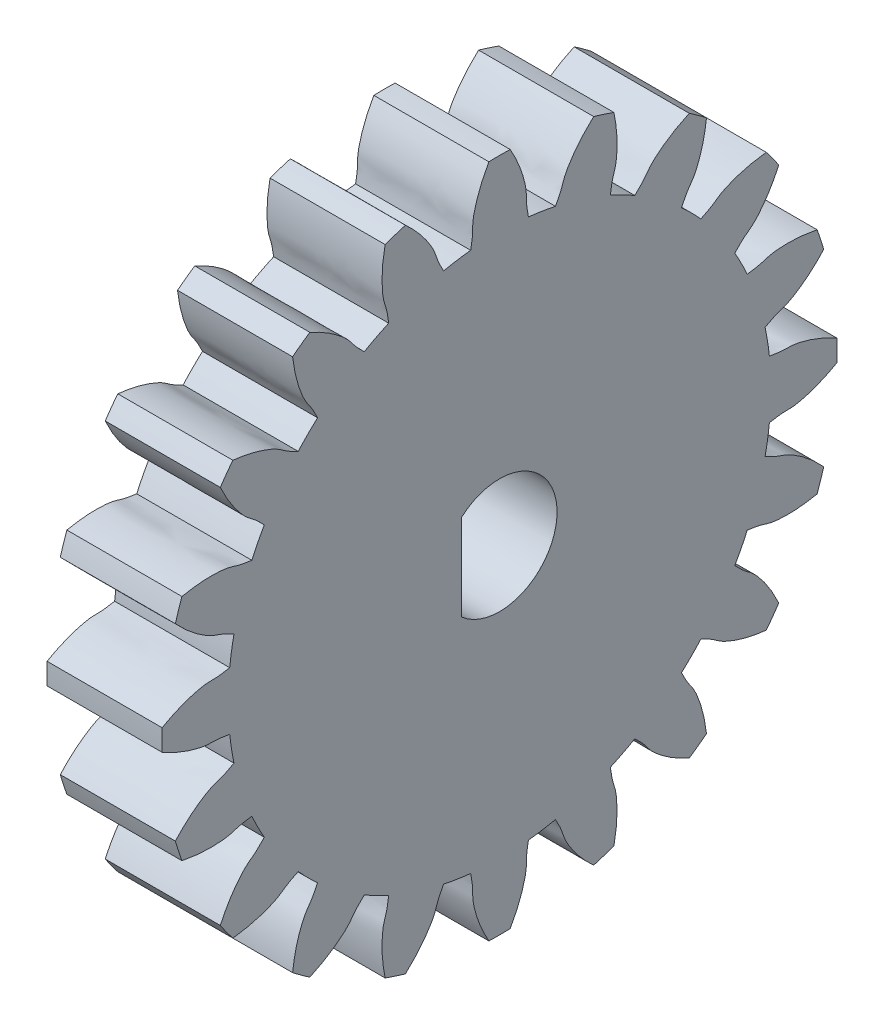
from build123d import *

# Parameters (mm, degrees)
SKETCH41_W          = 3
SKETCH41_H          = 8.8
CUT_EXTRUDE22_DEPTH = 4
CUT_EXTRUDE23_DEPTH = 4.0000001
CUT_EXTRUDE24_DEPTH = 4.0000001
CUT_EXTRUDE25_DEPTH = 4.0000001
CUT_EXTRUDE26_DEPTH = 4.0000001
CUT_EXTRUDE27_DEPTH = 4.0000001
CUT_EXTRUDE28_DEPTH = 4.0000001
CUT_EXTRUDE29_DEPTH = 4.0000001
CUT_EXTRUDE30_DEPTH = 4.0000001
CUT_EXTRUDE31_DEPTH = 4.0000001
CUT_EXTRUDE32_DEPTH = 4.0000001
CUT_EXTRUDE33_DEPTH = 4.0000001
CUT_EXTRUDE34_DEPTH = 4.0000001
CUT_EXTRUDE35_DEPTH = 4.0000001
CUT_EXTRUDE36_DEPTH = 4.0000001
CUT_EXTRUDE37_DEPTH = 4.0000001
CUT_EXTRUDE38_DEPTH = 4.0000001
CUT_EXTRUDE39_DEPTH = 4.0000001
CUT_EXTRUDE40_DEPTH = 4.0000001
CUT_EXTRUDE41_DEPTH = 4.0000001
SKETCH192_R         = 1.5
CUT_EXTRUDE42_DEPTH = 4.0000001
BOSS_EXTRUDE1_DEPTH = 3


with BuildPart() as part:
    # Sketch41 → Revolve3 (revolve)
    with BuildSketch(Plane.XY):
        with Locations((0, 4.4)):
            Rectangle(SKETCH41_W, SKETCH41_H)
    revolve(axis=Axis((-1.5, 0, 0), (1, 0, 0)))

    # Sketch47 → Cut-Extrude22 (cut, through all)
    with BuildSketch(Plane.ZY.offset(1.5)):
        with BuildLine():
            ThreePointArc((0.752371374, 7.034278405), (1.10668029, 6.987302347), (1.458164488, 6.922491725))
            add(Edge.make_bspline(
                [(1.458164488, 6.922491725), (1.494423107, 6.992924065), (1.531449224, 7.062967764), (1.566855162, 7.133832576), (1.636353022, 7.272932207), (1.667486777, 7.42948987), (1.74037045, 7.566845723), (1.810588583, 7.699178127), (1.894945412, 7.824180822), (1.98539454, 7.943601953), (2.0778826, 8.065715114), (2.179505836, 8.181201544), (2.2870056, 8.290332043), (2.341161164, 8.34530913), (2.396825306, 8.398829506), (2.453689093, 8.451000523)],
                knots=[-0.000236866, -0.000236866, -0.000236866, -0.000236866, 0, 0, 0, 0.000466485, 0.000466485, 0.000466485, 0.000915119, 0.000915119, 0.000915119, 0.001373742, 0.001373742, 0.001373742, 0.001604528, 0.001604528, 0.001604528, 0.001604528], degree=3))
            ThreePointArc((2.453689093, 8.451000523), (1.376623292, 8.691657397), (0.27790578, 8.795610745))
            add(Edge.make_bspline(
                [(0.27790578, 8.795610745), (0.315864725, 8.728421283), (0.352265764, 8.660319215), (0.386781912, 8.591297908), (0.467849437, 8.429188674), (0.538210762, 8.260953031), (0.593124703, 8.088222586), (0.648214325, 7.914939536), (0.696810293, 7.735248583), (0.700775261, 7.553462553), (0.702846258, 7.45851138), (0.700191106, 7.362781606), (0.71430769, 7.26886283), (0.726082314, 7.190525298), (0.739651946, 7.11246809), (0.752371374, 7.034278405)],
                knots=[-0.000231043, -0.000231043, -0.000231043, -0.000231043, 0, 0, 0, 0.000543748, 0.000543748, 0.000543748, 0.001090684, 0.001090684, 0.001090684, 0.001371999, 0.001371999, 0.001371999, 0.001605449, 0.001605449, 0.001605449, 0.001605449], degree=3))
        make_face()
    extrude(amount=-CUT_EXTRUDE22_DEPTH, mode=Mode.SUBTRACT)

    # Sketch54 → Cut-Extrude23 (cut, through all)
    with BuildSketch(Plane.ZY.offset(1.5)):
        with BuildLine():
            ThreePointArc((2.889259268, 6.457500774), (3.211710672, 6.303336412), (3.525964424, 6.133083257))
            add(Edge.make_bspline(
                [(3.525964424, 6.133083257), (3.58221321, 6.188863864), (3.639071834, 6.24403768), (3.694643313, 6.300493085), (3.803723856, 6.411308676), (3.881712795, 6.550583001), (3.993474579, 6.658693887), (4.101148954, 6.762850886), (4.220005023, 6.85566782), (4.342930415, 6.941293747), (4.468626829, 7.028849882), (4.600963539, 7.107280697), (4.736925069, 7.177850716), (4.805418925, 7.213402042), (4.874897376, 7.247101779), (4.945099782, 7.279147488)],
                knots=[-0.000236866, -0.000236866, -0.000236866, -0.000236866, 0, 0, 0, 0.000466485, 0.000466485, 0.000466485, 0.000915119, 0.000915119, 0.000915119, 0.001373742, 0.001373742, 0.001373742, 0.001604513, 0.001604513, 0.001604513, 0.001604513], degree=3))
            ThreePointArc((4.945099782, 7.279147488), (3.995116398, 7.840857413), (2.982297299, 8.279245305))
            add(Edge.make_bspline(
                [(2.982297299, 8.279245305), (2.997635716, 8.203614371), (3.011210464, 8.127596915), (3.022708515, 8.051287675), (3.049713804, 7.872061389), (3.064643729, 7.690316939), (3.063493347, 7.509071182), (3.062339284, 7.32724558), (3.053029237, 7.141332348), (3.000625173, 6.967218317), (2.973253282, 6.876274412), (2.941145956, 6.786050473), (2.925549127, 6.692366146), (2.912539832, 6.614224166), (2.901324315, 6.535794103), (2.889259268, 6.457500774)],
                knots=[-0.000231057, -0.000231057, -0.000231057, -0.000231057, 0, 0, 0, 0.000543748, 0.000543748, 0.000543748, 0.001090684, 0.001090684, 0.001090684, 0.001371999, 0.001371999, 0.001371999, 0.001605449, 0.001605449, 0.001605449, 0.001605449], degree=3))
        make_face()
    extrude(amount=-CUT_EXTRUDE23_DEPTH, mode=Mode.SUBTRACT)

    # Sketch61 → Cut-Extrude24 (cut, through all)
    with BuildSketch(Plane.ZY.offset(1.5)):
        with BuildLine():
            ThreePointArc((4.743326335, 5.248617975), (5.002356435, 5.00235599), (5.248618396, 4.743325868))
            add(Edge.make_bspline(
                [(5.248618396, 4.743325868), (5.319351326, 4.778994547), (5.390476738, 4.813897683), (5.460774034, 4.850417433), (5.598759696, 4.922101581), (5.715969719, 5.030459428), (5.855669593, 5.0987427), (5.990260291, 5.164528681), (6.13198114, 5.216074285), (6.275350002, 5.259523346), (6.421950729, 5.303951851), (6.572046874, 5.337649696), (6.723161308, 5.362751349), (6.799288801, 5.375396904), (6.875780525, 5.385977237), (6.95244965, 5.39476078)],
                knots=[-0.000236866, -0.000236866, -0.000236866, -0.000236866, 0, 0, 0, 0.000466485, 0.000466485, 0.000466485, 0.000915119, 0.000915119, 0.000915119, 0.001373742, 0.001373742, 0.001373742, 0.001604513, 0.001604513, 0.001604513, 0.001604513], degree=3))
            ThreePointArc((6.95244965, 5.39476078), (6.222539674, 6.222539674), (5.39476078, 6.95244965))
            add(Edge.make_bspline(
                [(5.39476078, 6.95244965), (5.385977237, 6.875780525), (5.375396904, 6.799288801), (5.362751349, 6.723161308), (5.333050936, 6.544361887), (5.291088015, 6.366899043), (5.233985917, 6.194879573), (5.176701137, 6.022309774), (5.110396409, 5.848372746), (5.006752987, 5.698974209), (4.95261756, 5.620939794), (4.894200948, 5.545053439), (4.850417433, 5.460774034), (4.813897658, 5.390476688), (4.778994845, 5.319351051), (4.743326335, 5.248617975)],
                knots=[-0.000231043, -0.000231043, -0.000231043, -0.000231043, 0, 0, 0, 0.000543748, 0.000543748, 0.000543748, 0.001090684, 0.001090684, 0.001090684, 0.001371999, 0.001371999, 0.001371999, 0.001605449, 0.001605449, 0.001605449, 0.001605449], degree=3))
        make_face()
    extrude(amount=-CUT_EXTRUDE24_DEPTH, mode=Mode.SUBTRACT)

    # Sketch68 → Cut-Extrude25 (cut, through all)
    with BuildSketch(Plane.ZY.offset(1.5)):
        with BuildLine():
            ThreePointArc((6.133083571, 3.525963879), (6.303336698, 3.211710111), (6.457501031, 2.889258694))
            add(Edge.make_bspline(
                [(6.457501031, 2.889258694), (6.535794272, 2.901323946), (6.614224221, 2.912539841), (6.692366146, 2.925549127), (6.845749929, 2.951084889), (6.9907077, 3.017919437), (7.144670867, 3.039691052), (7.293003214, 3.060666425), (7.443716219, 3.065895056), (7.593494607, 3.062914155), (7.746649347, 3.059866057), (7.899812471, 3.045532353), (8.051287675, 3.022708515), (8.127596915, 3.011210464), (8.203614371, 2.997635716), (8.279245305, 2.982297299)],
                knots=[-0.000236866, -0.000236866, -0.000236866, -0.000236866, 0, 0, 0, 0.000466485, 0.000466485, 0.000466485, 0.000915119, 0.000915119, 0.000915119, 0.001373742, 0.001373742, 0.001373742, 0.001604528, 0.001604528, 0.001604528, 0.001604528], degree=3))
            ThreePointArc((8.279245305, 2.982297299), (7.840857413, 3.995116398), (7.279147488, 4.945099782))
            add(Edge.make_bspline(
                [(7.279147488, 4.945099782), (7.247101779, 4.874897376), (7.213402042, 4.805418925), (7.177850716, 4.736925069), (7.094351885, 4.576054646), (6.99960374, 4.420244708), (6.892139479, 4.274289989), (6.784331415, 4.127868327), (6.667522373, 3.982933671), (6.522784935, 3.872874798), (6.447185124, 3.815388426), (6.368177451, 3.76126794), (6.300493085, 3.694643313), (6.244037641, 3.639071795), (6.188864062, 3.582212857), (6.133083571, 3.525963879)],
                knots=[-0.000231043, -0.000231043, -0.000231043, -0.000231043, 0, 0, 0, 0.000543748, 0.000543748, 0.000543748, 0.001090684, 0.001090684, 0.001090684, 0.001371999, 0.001371999, 0.001371999, 0.001605449, 0.001605449, 0.001605449, 0.001605449], degree=3))
        make_face()
    extrude(amount=-CUT_EXTRUDE25_DEPTH, mode=Mode.SUBTRACT)

    # Sketch75 → Cut-Extrude26 (cut, through all)
    with BuildSketch(Plane.ZY.offset(1.5)):
        with BuildLine():
            ThreePointArc((6.922491855, 1.458163872), (6.987302446, 1.106679669), (7.034278472, 0.752370749))
            add(Edge.make_bspline(
                [(7.034278472, 0.752370749), (7.112468137, 0.739651543), (7.190525353, 0.726082306), (7.26886283, 0.71430769), (7.422630461, 0.691195446), (7.581146506, 0.709964464), (7.734301978, 0.683093265), (7.88185617, 0.657204814), (8.026808491, 0.615604659), (8.168335054, 0.566485586), (8.313051953, 0.516259255), (8.454289382, 0.455297084), (8.591297908, 0.386781912), (8.660319215, 0.352265764), (8.728421283, 0.315864725), (8.795610745, 0.27790578)],
                knots=[-0.000236866, -0.000236866, -0.000236866, -0.000236866, 0, 0, 0, 0.000466485, 0.000466485, 0.000466485, 0.000915119, 0.000915119, 0.000915119, 0.001373742, 0.001373742, 0.001373742, 0.001604513, 0.001604513, 0.001604513, 0.001604513], degree=3))
            ThreePointArc((8.795610745, 0.27790578), (8.691657397, 1.376623292), (8.451000523, 2.453689093))
            add(Edge.make_bspline(
                [(8.451000523, 2.453689093), (8.398829506, 2.396825306), (8.34530913, 2.341161164), (8.290332043, 2.2870056), (8.161208242, 2.159811294), (8.022949483, 2.040906024), (7.875642408, 1.93530312), (7.727864065, 1.829362368), (7.571984792, 1.727617298), (7.400321246, 1.667671417), (7.310657288, 1.636360256), (7.218792375, 1.609303328), (7.133832576, 1.566855162), (7.062967715, 1.531449199), (6.992924145, 1.494422709), (6.922491855, 1.458163872)],
                knots=[-0.000231043, -0.000231043, -0.000231043, -0.000231043, 0, 0, 0, 0.000543748, 0.000543748, 0.000543748, 0.001090684, 0.001090684, 0.001090684, 0.001371999, 0.001371999, 0.001371999, 0.001605449, 0.001605449, 0.001605449, 0.001605449], degree=3))
        make_face()
    extrude(amount=-CUT_EXTRUDE26_DEPTH, mode=Mode.SUBTRACT)

    # Sketch82 → Cut-Extrude27 (cut, through all)
    with BuildSketch(Plane.ZY.offset(1.5)):
        with BuildLine():
            ThreePointArc((8.451000523, -2.453689093), (8.691657397, -1.376623292), (8.795610745, -0.27790578))
            add(Edge.make_bspline(
                [(8.795610745, -0.27790578), (8.728421283, -0.315864725), (8.660319215, -0.352265764), (8.591297908, -0.386781912), (8.429188674, -0.467849437), (8.260953031, -0.538210762), (8.088222586, -0.593124703), (7.914939536, -0.648214325), (7.735248583, -0.696810293), (7.553462553, -0.700775261), (7.45851138, -0.702846258), (7.362781606, -0.700191106), (7.26886283, -0.71430769), (7.190525298, -0.726082314), (7.11246809, -0.739651946), (7.034278405, -0.752371374)],
                knots=[-0.000231043, -0.000231043, -0.000231043, -0.000231043, 0, 0, 0, 0.000543748, 0.000543748, 0.000543748, 0.001090684, 0.001090684, 0.001090684, 0.001371999, 0.001371999, 0.001371999, 0.001605449, 0.001605449, 0.001605449, 0.001605449], degree=3))
            ThreePointArc((7.034278405, -0.752371374), (6.987302347, -1.10668029), (6.922491725, -1.458164488))
            add(Edge.make_bspline(
                [(6.922491725, -1.458164488), (6.992924065, -1.494423107), (7.062967764, -1.531449224), (7.133832576, -1.566855162), (7.272932207, -1.636353022), (7.42948987, -1.667486777), (7.566845723, -1.74037045), (7.699178127, -1.810588583), (7.824180822, -1.894945412), (7.943601953, -1.98539454), (8.065715114, -2.0778826), (8.181201544, -2.179505836), (8.290332043, -2.2870056), (8.34530913, -2.341161164), (8.398829506, -2.396825306), (8.451000523, -2.453689093)],
                knots=[-0.000236866, -0.000236866, -0.000236866, -0.000236866, 0, 0, 0, 0.000466485, 0.000466485, 0.000466485, 0.000915119, 0.000915119, 0.000915119, 0.001373742, 0.001373742, 0.001373742, 0.001604513, 0.001604513, 0.001604513, 0.001604513], degree=3))
        make_face()
    extrude(amount=-CUT_EXTRUDE27_DEPTH, mode=Mode.SUBTRACT)

    # Sketch89 → Cut-Extrude28 (cut, through all)
    with BuildSketch(Plane.ZY.offset(1.5)):
        with BuildLine():
            ThreePointArc((7.279147488, -4.945099782), (7.840857413, -3.995116398), (8.279245305, -2.982297299))
            add(Edge.make_bspline(
                [(8.279245305, -2.982297299), (8.203614371, -2.997635716), (8.127596915, -3.011210464), (8.051287675, -3.022708515), (7.872061389, -3.049713804), (7.690316939, -3.064643729), (7.509071182, -3.063493347), (7.32724558, -3.062339284), (7.141332348, -3.053029237), (6.967218317, -3.000625173), (6.876274412, -2.973253282), (6.786050473, -2.941145956), (6.692366146, -2.925549127), (6.614224166, -2.912539832), (6.535794103, -2.901324315), (6.457500774, -2.889259268)],
                knots=[-0.000231057, -0.000231057, -0.000231057, -0.000231057, 0, 0, 0, 0.000543748, 0.000543748, 0.000543748, 0.001090684, 0.001090684, 0.001090684, 0.001371999, 0.001371999, 0.001371999, 0.001605449, 0.001605449, 0.001605449, 0.001605449], degree=3))
            ThreePointArc((6.457500774, -2.889259268), (6.303336412, -3.211710672), (6.133083257, -3.525964424))
            add(Edge.make_bspline(
                [(6.133083257, -3.525964424), (6.188863864, -3.58221321), (6.24403768, -3.639071834), (6.300493085, -3.694643313), (6.411308676, -3.803723856), (6.550583001, -3.881712795), (6.658693887, -3.993474579), (6.762850886, -4.101148954), (6.85566782, -4.220005023), (6.941293747, -4.342930415), (7.028849882, -4.468626829), (7.107280697, -4.600963539), (7.177850716, -4.736925069), (7.213402042, -4.805418925), (7.247101779, -4.874897376), (7.279147488, -4.945099782)],
                knots=[-0.000236866, -0.000236866, -0.000236866, -0.000236866, 0, 0, 0, 0.000466485, 0.000466485, 0.000466485, 0.000915119, 0.000915119, 0.000915119, 0.001373742, 0.001373742, 0.001373742, 0.001604513, 0.001604513, 0.001604513, 0.001604513], degree=3))
        make_face()
    extrude(amount=-CUT_EXTRUDE28_DEPTH, mode=Mode.SUBTRACT)

    # Sketch96 → Cut-Extrude29 (cut, through all)
    with BuildSketch(Plane.ZY.offset(1.5)):
        with BuildLine():
            ThreePointArc((5.39476078, -6.95244965), (6.222539674, -6.222539674), (6.95244965, -5.39476078))
            add(Edge.make_bspline(
                [(6.95244965, -5.39476078), (6.875780525, -5.385977237), (6.799288801, -5.375396904), (6.723161308, -5.362751349), (6.544361887, -5.333050936), (6.366899043, -5.291088015), (6.194879573, -5.233985917), (6.022309774, -5.176701137), (5.848372746, -5.110396409), (5.698974209, -5.006752987), (5.620939794, -4.95261756), (5.545053439, -4.894200948), (5.460774034, -4.850417433), (5.390476688, -4.813897658), (5.319351051, -4.778994845), (5.248617975, -4.743326335)],
                knots=[-0.000231043, -0.000231043, -0.000231043, -0.000231043, 0, 0, 0, 0.000543748, 0.000543748, 0.000543748, 0.001090684, 0.001090684, 0.001090684, 0.001371999, 0.001371999, 0.001371999, 0.001605449, 0.001605449, 0.001605449, 0.001605449], degree=3))
            ThreePointArc((5.248617975, -4.743326335), (5.00235599, -5.002356435), (4.743325868, -5.248618396))
            add(Edge.make_bspline(
                [(4.743325868, -5.248618396), (4.778994547, -5.319351326), (4.813897683, -5.390476738), (4.850417433, -5.460774034), (4.922101581, -5.598759696), (5.030459428, -5.715969719), (5.0987427, -5.855669593), (5.164528681, -5.990260291), (5.216074285, -6.13198114), (5.259523346, -6.275350002), (5.303951851, -6.421950729), (5.337649696, -6.572046874), (5.362751349, -6.723161308), (5.375396904, -6.799288801), (5.385977237, -6.875780525), (5.39476078, -6.95244965)],
                knots=[-0.000236866, -0.000236866, -0.000236866, -0.000236866, 0, 0, 0, 0.000466485, 0.000466485, 0.000466485, 0.000915119, 0.000915119, 0.000915119, 0.001373742, 0.001373742, 0.001373742, 0.001604513, 0.001604513, 0.001604513, 0.001604513], degree=3))
        make_face()
    extrude(amount=-CUT_EXTRUDE29_DEPTH, mode=Mode.SUBTRACT)

    # Sketch103 → Cut-Extrude30 (cut, through all)
    with BuildSketch(Plane.ZY.offset(1.5)):
        with BuildLine():
            ThreePointArc((2.982297299, -8.279245305), (3.995116398, -7.840857413), (4.945099782, -7.279147488))
            add(Edge.make_bspline(
                [(4.945099782, -7.279147488), (4.874897376, -7.247101779), (4.805418925, -7.213402042), (4.736925069, -7.177850716), (4.576054646, -7.094351885), (4.420244708, -6.99960374), (4.274289989, -6.892139479), (4.127868327, -6.784331415), (3.982933671, -6.667522373), (3.872874798, -6.522784935), (3.815388426, -6.447185124), (3.76126794, -6.368177451), (3.694643313, -6.300493085), (3.639071795, -6.244037641), (3.582212857, -6.188864062), (3.525963879, -6.133083571)],
                knots=[-0.000231043, -0.000231043, -0.000231043, -0.000231043, 0, 0, 0, 0.000543748, 0.000543748, 0.000543748, 0.001090684, 0.001090684, 0.001090684, 0.001371999, 0.001371999, 0.001371999, 0.001605449, 0.001605449, 0.001605449, 0.001605449], degree=3))
            ThreePointArc((3.525963879, -6.133083571), (3.211710111, -6.303336698), (2.889258694, -6.457501031))
            add(Edge.make_bspline(
                [(2.889258694, -6.457501031), (2.901323946, -6.535794272), (2.912539841, -6.614224221), (2.925549127, -6.692366146), (2.951084889, -6.845749929), (3.017919437, -6.9907077), (3.039691052, -7.144670867), (3.060666425, -7.293003214), (3.065895056, -7.443716219), (3.062914155, -7.593494607), (3.059866057, -7.746649347), (3.045532353, -7.899812471), (3.022708515, -8.051287675), (3.011210464, -8.127596915), (2.997635716, -8.203614371), (2.982297299, -8.279245305)],
                knots=[-0.000236866, -0.000236866, -0.000236866, -0.000236866, 0, 0, 0, 0.000466485, 0.000466485, 0.000466485, 0.000915119, 0.000915119, 0.000915119, 0.001373742, 0.001373742, 0.001373742, 0.001604528, 0.001604528, 0.001604528, 0.001604528], degree=3))
        make_face()
    extrude(amount=-CUT_EXTRUDE30_DEPTH, mode=Mode.SUBTRACT)

    # Sketch110 → Cut-Extrude31 (cut, through all)
    with BuildSketch(Plane.ZY.offset(1.5)):
        with BuildLine():
            ThreePointArc((0.27790578, -8.795610745), (1.376623292, -8.691657397), (2.453689093, -8.451000523))
            add(Edge.make_bspline(
                [(2.453689093, -8.451000523), (2.396825306, -8.398829506), (2.341161164, -8.34530913), (2.2870056, -8.290332043), (2.159811294, -8.161208242), (2.040906024, -8.022949483), (1.93530312, -7.875642408), (1.829362368, -7.727864065), (1.727617298, -7.571984792), (1.667671417, -7.400321246), (1.636360256, -7.310657288), (1.609303328, -7.218792375), (1.566855162, -7.133832576), (1.531449199, -7.062967715), (1.494422709, -6.992924145), (1.458163872, -6.922491855)],
                knots=[-0.000231057, -0.000231057, -0.000231057, -0.000231057, 0, 0, 0, 0.000543748, 0.000543748, 0.000543748, 0.001090684, 0.001090684, 0.001090684, 0.001371999, 0.001371999, 0.001371999, 0.001605449, 0.001605449, 0.001605449, 0.001605449], degree=3))
            ThreePointArc((1.458163872, -6.922491855), (1.106679669, -6.987302446), (0.752370749, -7.034278472))
            add(Edge.make_bspline(
                [(0.752370749, -7.034278472), (0.739651543, -7.112468137), (0.726082306, -7.190525353), (0.71430769, -7.26886283), (0.691195446, -7.422630461), (0.709964464, -7.581146506), (0.683093265, -7.734301978), (0.657204814, -7.88185617), (0.615604659, -8.026808491), (0.566485586, -8.168335054), (0.516259255, -8.313051953), (0.455297084, -8.454289382), (0.386781912, -8.591297908), (0.352265764, -8.660319215), (0.315864725, -8.728421283), (0.27790578, -8.795610745)],
                knots=[-0.000236866, -0.000236866, -0.000236866, -0.000236866, 0, 0, 0, 0.000466485, 0.000466485, 0.000466485, 0.000915119, 0.000915119, 0.000915119, 0.001373742, 0.001373742, 0.001373742, 0.001604513, 0.001604513, 0.001604513, 0.001604513], degree=3))
        make_face()
    extrude(amount=-CUT_EXTRUDE31_DEPTH, mode=Mode.SUBTRACT)

    # Sketch117 → Cut-Extrude32 (cut, through all)
    with BuildSketch(Plane.ZY.offset(1.5)):
        with BuildLine():
            ThreePointArc((-0.752371374, -7.034278405), (-1.10668029, -6.987302347), (-1.458164488, -6.922491725))
            add(Edge.make_bspline(
                [(-1.458164488, -6.922491725), (-1.494423107, -6.992924065), (-1.531449224, -7.062967764), (-1.566855162, -7.133832576), (-1.636353022, -7.272932207), (-1.667486777, -7.42948987), (-1.74037045, -7.566845723), (-1.810588583, -7.699178127), (-1.894945412, -7.824180822), (-1.98539454, -7.943601953), (-2.0778826, -8.065715114), (-2.179505836, -8.181201544), (-2.2870056, -8.290332043), (-2.341161164, -8.34530913), (-2.396825306, -8.398829506), (-2.453689093, -8.451000523)],
                knots=[-0.000236866, -0.000236866, -0.000236866, -0.000236866, 0, 0, 0, 0.000466485, 0.000466485, 0.000466485, 0.000915119, 0.000915119, 0.000915119, 0.001373742, 0.001373742, 0.001373742, 0.001604528, 0.001604528, 0.001604528, 0.001604528], degree=3))
            ThreePointArc((-2.453689093, -8.451000523), (-1.376623292, -8.691657397), (-0.27790578, -8.795610745))
            add(Edge.make_bspline(
                [(-0.27790578, -8.795610745), (-0.315864725, -8.728421283), (-0.352265764, -8.660319215), (-0.386781912, -8.591297908), (-0.467849437, -8.429188674), (-0.538210762, -8.260953031), (-0.593124703, -8.088222586), (-0.648214325, -7.914939536), (-0.696810293, -7.735248583), (-0.700775261, -7.553462553), (-0.702846258, -7.45851138), (-0.700191106, -7.362781606), (-0.71430769, -7.26886283), (-0.726082314, -7.190525298), (-0.739651946, -7.11246809), (-0.752371374, -7.034278405)],
                knots=[-0.000231043, -0.000231043, -0.000231043, -0.000231043, 0, 0, 0, 0.000543748, 0.000543748, 0.000543748, 0.001090684, 0.001090684, 0.001090684, 0.001371999, 0.001371999, 0.001371999, 0.001605449, 0.001605449, 0.001605449, 0.001605449], degree=3))
        make_face()
    extrude(amount=-CUT_EXTRUDE32_DEPTH, mode=Mode.SUBTRACT)

    # Sketch124 → Cut-Extrude33 (cut, through all)
    with BuildSketch(Plane.ZY.offset(1.5)):
        with BuildLine():
            ThreePointArc((-2.889259268, -6.457500774), (-3.211710672, -6.303336412), (-3.525964424, -6.133083257))
            add(Edge.make_bspline(
                [(-3.525964424, -6.133083257), (-3.58221321, -6.188863864), (-3.639071834, -6.24403768), (-3.694643313, -6.300493085), (-3.803723856, -6.411308676), (-3.881712795, -6.550583001), (-3.993474579, -6.658693887), (-4.101148954, -6.762850886), (-4.220005023, -6.85566782), (-4.342930415, -6.941293747), (-4.468626829, -7.028849882), (-4.600963539, -7.107280697), (-4.736925069, -7.177850716), (-4.805418925, -7.213402042), (-4.874897376, -7.247101779), (-4.945099782, -7.279147488)],
                knots=[-0.000236866, -0.000236866, -0.000236866, -0.000236866, 0, 0, 0, 0.000466485, 0.000466485, 0.000466485, 0.000915119, 0.000915119, 0.000915119, 0.001373742, 0.001373742, 0.001373742, 0.001604513, 0.001604513, 0.001604513, 0.001604513], degree=3))
            ThreePointArc((-4.945099782, -7.279147488), (-3.995116398, -7.840857413), (-2.982297299, -8.279245305))
            add(Edge.make_bspline(
                [(-2.982297299, -8.279245305), (-2.997635716, -8.203614371), (-3.011210464, -8.127596915), (-3.022708515, -8.051287675), (-3.049713804, -7.872061389), (-3.064643729, -7.690316939), (-3.063493347, -7.509071182), (-3.062339284, -7.32724558), (-3.053029237, -7.141332348), (-3.000625173, -6.967218317), (-2.973253282, -6.876274412), (-2.941145956, -6.786050473), (-2.925549127, -6.692366146), (-2.912539832, -6.614224166), (-2.901324315, -6.535794103), (-2.889259268, -6.457500774)],
                knots=[-0.000231057, -0.000231057, -0.000231057, -0.000231057, 0, 0, 0, 0.000543748, 0.000543748, 0.000543748, 0.001090684, 0.001090684, 0.001090684, 0.001371999, 0.001371999, 0.001371999, 0.001605449, 0.001605449, 0.001605449, 0.001605449], degree=3))
        make_face()
    extrude(amount=-CUT_EXTRUDE33_DEPTH, mode=Mode.SUBTRACT)

    # Sketch131 → Cut-Extrude34 (cut, through all)
    with BuildSketch(Plane.ZY.offset(1.5)):
        with BuildLine():
            ThreePointArc((-6.95244965, -5.39476078), (-6.222539674, -6.222539674), (-5.39476078, -6.95244965))
            add(Edge.make_bspline(
                [(-5.39476078, -6.95244965), (-5.385977237, -6.875780525), (-5.375396904, -6.799288801), (-5.362751349, -6.723161308), (-5.333050936, -6.544361887), (-5.291088015, -6.366899043), (-5.233985917, -6.194879573), (-5.176701137, -6.022309774), (-5.110396409, -5.848372746), (-5.006752987, -5.698974209), (-4.95261756, -5.620939794), (-4.894200948, -5.545053439), (-4.850417433, -5.460774034), (-4.813897658, -5.390476688), (-4.778994845, -5.319351051), (-4.743326335, -5.248617975)],
                knots=[-0.000231043, -0.000231043, -0.000231043, -0.000231043, 0, 0, 0, 0.000543748, 0.000543748, 0.000543748, 0.001090684, 0.001090684, 0.001090684, 0.001371999, 0.001371999, 0.001371999, 0.001605449, 0.001605449, 0.001605449, 0.001605449], degree=3))
            ThreePointArc((-4.743326335, -5.248617975), (-5.002356435, -5.00235599), (-5.248618396, -4.743325868))
            add(Edge.make_bspline(
                [(-5.248618396, -4.743325868), (-5.319351326, -4.778994547), (-5.390476738, -4.813897683), (-5.460774034, -4.850417433), (-5.598759696, -4.922101581), (-5.715969719, -5.030459428), (-5.855669593, -5.0987427), (-5.990260291, -5.164528681), (-6.13198114, -5.216074285), (-6.275350002, -5.259523346), (-6.421950729, -5.303951851), (-6.572046874, -5.337649696), (-6.723161308, -5.362751349), (-6.799288801, -5.375396904), (-6.875780525, -5.385977237), (-6.95244965, -5.39476078)],
                knots=[-0.000236866, -0.000236866, -0.000236866, -0.000236866, 0, 0, 0, 0.000466485, 0.000466485, 0.000466485, 0.000915119, 0.000915119, 0.000915119, 0.001373742, 0.001373742, 0.001373742, 0.001604513, 0.001604513, 0.001604513, 0.001604513], degree=3))
        make_face()
    extrude(amount=-CUT_EXTRUDE34_DEPTH, mode=Mode.SUBTRACT)

    # Sketch138 → Cut-Extrude35 (cut, through all)
    with BuildSketch(Plane.ZY.offset(1.5)):
        with BuildLine():
            ThreePointArc((-8.279245305, -2.982297299), (-7.840857413, -3.995116398), (-7.279147488, -4.945099782))
            add(Edge.make_bspline(
                [(-7.279147488, -4.945099782), (-7.247101779, -4.874897376), (-7.213402042, -4.805418925), (-7.177850716, -4.736925069), (-7.094351885, -4.576054646), (-6.99960374, -4.420244708), (-6.892139479, -4.274289989), (-6.784331415, -4.127868327), (-6.667522373, -3.982933671), (-6.522784935, -3.872874798), (-6.447185124, -3.815388426), (-6.368177451, -3.76126794), (-6.300493085, -3.694643313), (-6.244037641, -3.639071795), (-6.188864062, -3.582212857), (-6.133083571, -3.525963879)],
                knots=[-0.000231043, -0.000231043, -0.000231043, -0.000231043, 0, 0, 0, 0.000543748, 0.000543748, 0.000543748, 0.001090684, 0.001090684, 0.001090684, 0.001371999, 0.001371999, 0.001371999, 0.001605449, 0.001605449, 0.001605449, 0.001605449], degree=3))
            ThreePointArc((-6.133083571, -3.525963879), (-6.303336698, -3.211710111), (-6.457501031, -2.889258694))
            add(Edge.make_bspline(
                [(-6.457501031, -2.889258694), (-6.535794272, -2.901323946), (-6.614224221, -2.912539841), (-6.692366146, -2.925549127), (-6.845749929, -2.951084889), (-6.9907077, -3.017919437), (-7.144670867, -3.039691052), (-7.293003214, -3.060666425), (-7.443716219, -3.065895056), (-7.593494607, -3.062914155), (-7.746649347, -3.059866057), (-7.899812471, -3.045532353), (-8.051287675, -3.022708515), (-8.127596915, -3.011210464), (-8.203614371, -2.997635716), (-8.279245305, -2.982297299)],
                knots=[-0.000236866, -0.000236866, -0.000236866, -0.000236866, 0, 0, 0, 0.000466485, 0.000466485, 0.000466485, 0.000915119, 0.000915119, 0.000915119, 0.001373742, 0.001373742, 0.001373742, 0.001604528, 0.001604528, 0.001604528, 0.001604528], degree=3))
        make_face()
    extrude(amount=-CUT_EXTRUDE35_DEPTH, mode=Mode.SUBTRACT)

    # Sketch145 → Cut-Extrude36 (cut, through all)
    with BuildSketch(Plane.ZY.offset(1.5)):
        with BuildLine():
            ThreePointArc((-8.795610745, -0.27790578), (-8.691657397, -1.376623292), (-8.451000523, -2.453689093))
            add(Edge.make_bspline(
                [(-8.451000523, -2.453689093), (-8.398829506, -2.396825306), (-8.34530913, -2.341161164), (-8.290332043, -2.2870056), (-8.161208242, -2.159811294), (-8.022949483, -2.040906024), (-7.875642408, -1.93530312), (-7.727864065, -1.829362368), (-7.571984792, -1.727617298), (-7.400321246, -1.667671417), (-7.310657288, -1.636360256), (-7.218792375, -1.609303328), (-7.133832576, -1.566855162), (-7.062967715, -1.531449199), (-6.992924145, -1.494422709), (-6.922491855, -1.458163872)],
                knots=[-0.000231043, -0.000231043, -0.000231043, -0.000231043, 0, 0, 0, 0.000543748, 0.000543748, 0.000543748, 0.001090684, 0.001090684, 0.001090684, 0.001371999, 0.001371999, 0.001371999, 0.001605449, 0.001605449, 0.001605449, 0.001605449], degree=3))
            ThreePointArc((-6.922491855, -1.458163872), (-6.987302446, -1.106679669), (-7.034278472, -0.752370749))
            add(Edge.make_bspline(
                [(-7.034278472, -0.752370749), (-7.112468137, -0.739651543), (-7.190525353, -0.726082306), (-7.26886283, -0.71430769), (-7.422630461, -0.691195446), (-7.581146506, -0.709964464), (-7.734301978, -0.683093265), (-7.88185617, -0.657204814), (-8.026808491, -0.615604659), (-8.168335054, -0.566485586), (-8.313051953, -0.516259255), (-8.454289382, -0.455297084), (-8.591297908, -0.386781912), (-8.660319215, -0.352265764), (-8.728421283, -0.315864725), (-8.795610745, -0.27790578)],
                knots=[-0.000236866, -0.000236866, -0.000236866, -0.000236866, 0, 0, 0, 0.000466485, 0.000466485, 0.000466485, 0.000915119, 0.000915119, 0.000915119, 0.001373742, 0.001373742, 0.001373742, 0.001604513, 0.001604513, 0.001604513, 0.001604513], degree=3))
        make_face()
    extrude(amount=-CUT_EXTRUDE36_DEPTH, mode=Mode.SUBTRACT)

    # Sketch152 → Cut-Extrude37 (cut, through all)
    with BuildSketch(Plane.ZY.offset(1.5)):
        with BuildLine():
            ThreePointArc((-8.451000523, 2.453689093), (-8.691657397, 1.376623292), (-8.795610745, 0.27790578))
            add(Edge.make_bspline(
                [(-8.795610745, 0.27790578), (-8.728421283, 0.315864725), (-8.660319215, 0.352265764), (-8.591297908, 0.386781912), (-8.429188674, 0.467849437), (-8.260953031, 0.538210762), (-8.088222586, 0.593124703), (-7.914939536, 0.648214325), (-7.735248583, 0.696810293), (-7.553462553, 0.700775261), (-7.45851138, 0.702846258), (-7.362781606, 0.700191106), (-7.26886283, 0.71430769), (-7.190525298, 0.726082314), (-7.11246809, 0.739651946), (-7.034278405, 0.752371374)],
                knots=[-0.000231043, -0.000231043, -0.000231043, -0.000231043, 0, 0, 0, 0.000543748, 0.000543748, 0.000543748, 0.001090684, 0.001090684, 0.001090684, 0.001371999, 0.001371999, 0.001371999, 0.001605449, 0.001605449, 0.001605449, 0.001605449], degree=3))
            ThreePointArc((-7.034278405, 0.752371374), (-6.987302347, 1.10668029), (-6.922491725, 1.458164488))
            add(Edge.make_bspline(
                [(-6.922491725, 1.458164488), (-6.992924065, 1.494423107), (-7.062967764, 1.531449224), (-7.133832576, 1.566855162), (-7.272932207, 1.636353022), (-7.42948987, 1.667486777), (-7.566845723, 1.74037045), (-7.699178127, 1.810588583), (-7.824180822, 1.894945412), (-7.943601953, 1.98539454), (-8.065715114, 2.0778826), (-8.181201544, 2.179505836), (-8.290332043, 2.2870056), (-8.34530913, 2.341161164), (-8.398829506, 2.396825306), (-8.451000523, 2.453689093)],
                knots=[-0.000236866, -0.000236866, -0.000236866, -0.000236866, 0, 0, 0, 0.000466485, 0.000466485, 0.000466485, 0.000915119, 0.000915119, 0.000915119, 0.001373742, 0.001373742, 0.001373742, 0.001604513, 0.001604513, 0.001604513, 0.001604513], degree=3))
        make_face()
    extrude(amount=-CUT_EXTRUDE37_DEPTH, mode=Mode.SUBTRACT)

    # Sketch159 → Cut-Extrude38 (cut, through all)
    with BuildSketch(Plane.ZY.offset(1.5)):
        with BuildLine():
            ThreePointArc((-7.279147488, 4.945099782), (-7.840857413, 3.995116398), (-8.279245305, 2.982297299))
            add(Edge.make_bspline(
                [(-8.279245305, 2.982297299), (-8.203614371, 2.997635716), (-8.127596915, 3.011210464), (-8.051287675, 3.022708515), (-7.872061389, 3.049713804), (-7.690316939, 3.064643729), (-7.509071182, 3.063493347), (-7.32724558, 3.062339284), (-7.141332348, 3.053029237), (-6.967218317, 3.000625173), (-6.876274412, 2.973253282), (-6.786050473, 2.941145956), (-6.692366146, 2.925549127), (-6.614224166, 2.912539832), (-6.535794103, 2.901324315), (-6.457500774, 2.889259268)],
                knots=[-0.000231057, -0.000231057, -0.000231057, -0.000231057, 0, 0, 0, 0.000543748, 0.000543748, 0.000543748, 0.001090684, 0.001090684, 0.001090684, 0.001371999, 0.001371999, 0.001371999, 0.001605449, 0.001605449, 0.001605449, 0.001605449], degree=3))
            ThreePointArc((-6.457500774, 2.889259268), (-6.303336412, 3.211710672), (-6.133083257, 3.525964424))
            add(Edge.make_bspline(
                [(-6.133083257, 3.525964424), (-6.188863864, 3.58221321), (-6.24403768, 3.639071834), (-6.300493085, 3.694643313), (-6.411308676, 3.803723856), (-6.550583001, 3.881712795), (-6.658693887, 3.993474579), (-6.762850886, 4.101148954), (-6.85566782, 4.220005023), (-6.941293747, 4.342930415), (-7.028849882, 4.468626829), (-7.107280697, 4.600963539), (-7.177850716, 4.736925069), (-7.213402042, 4.805418925), (-7.247101779, 4.874897376), (-7.279147488, 4.945099782)],
                knots=[-0.000236866, -0.000236866, -0.000236866, -0.000236866, 0, 0, 0, 0.000466485, 0.000466485, 0.000466485, 0.000915119, 0.000915119, 0.000915119, 0.001373742, 0.001373742, 0.001373742, 0.001604513, 0.001604513, 0.001604513, 0.001604513], degree=3))
        make_face()
    extrude(amount=-CUT_EXTRUDE38_DEPTH, mode=Mode.SUBTRACT)

    # Sketch166 → Cut-Extrude39 (cut, through all)
    with BuildSketch(Plane.ZY.offset(1.5)):
        with BuildLine():
            ThreePointArc((-5.39476078, 6.95244965), (-6.222539674, 6.222539674), (-6.95244965, 5.39476078))
            add(Edge.make_bspline(
                [(-6.95244965, 5.39476078), (-6.875780525, 5.385977237), (-6.799288801, 5.375396904), (-6.723161308, 5.362751349), (-6.544361887, 5.333050936), (-6.366899043, 5.291088015), (-6.194879573, 5.233985917), (-6.022309774, 5.176701137), (-5.848372746, 5.110396409), (-5.698974209, 5.006752987), (-5.620939794, 4.95261756), (-5.545053439, 4.894200948), (-5.460774034, 4.850417433), (-5.390476688, 4.813897658), (-5.319351051, 4.778994845), (-5.248617975, 4.743326335)],
                knots=[-0.000231043, -0.000231043, -0.000231043, -0.000231043, 0, 0, 0, 0.000543748, 0.000543748, 0.000543748, 0.001090684, 0.001090684, 0.001090684, 0.001371999, 0.001371999, 0.001371999, 0.001605449, 0.001605449, 0.001605449, 0.001605449], degree=3))
            ThreePointArc((-5.248617975, 4.743326335), (-5.00235599, 5.002356435), (-4.743325868, 5.248618396))
            add(Edge.make_bspline(
                [(-4.743325868, 5.248618396), (-4.778994547, 5.319351326), (-4.813897683, 5.390476738), (-4.850417433, 5.460774034), (-4.922101581, 5.598759696), (-5.030459428, 5.715969719), (-5.0987427, 5.855669593), (-5.164528681, 5.990260291), (-5.216074285, 6.13198114), (-5.259523346, 6.275350002), (-5.303951851, 6.421950729), (-5.337649696, 6.572046874), (-5.362751349, 6.723161308), (-5.375396904, 6.799288801), (-5.385977237, 6.875780525), (-5.39476078, 6.95244965)],
                knots=[-0.000236866, -0.000236866, -0.000236866, -0.000236866, 0, 0, 0, 0.000466485, 0.000466485, 0.000466485, 0.000915119, 0.000915119, 0.000915119, 0.001373742, 0.001373742, 0.001373742, 0.001604513, 0.001604513, 0.001604513, 0.001604513], degree=3))
        make_face()
    extrude(amount=-CUT_EXTRUDE39_DEPTH, mode=Mode.SUBTRACT)

    # Sketch173 → Cut-Extrude40 (cut, through all)
    with BuildSketch(Plane.ZY.offset(1.5)):
        with BuildLine():
            ThreePointArc((-2.982297299, 8.279245305), (-3.995116398, 7.840857413), (-4.945099782, 7.279147488))
            add(Edge.make_bspline(
                [(-4.945099782, 7.279147488), (-4.874897376, 7.247101779), (-4.805418925, 7.213402042), (-4.736925069, 7.177850716), (-4.576054646, 7.094351885), (-4.420244708, 6.99960374), (-4.274289989, 6.892139479), (-4.127868327, 6.784331415), (-3.982933671, 6.667522373), (-3.872874798, 6.522784935), (-3.815388426, 6.447185124), (-3.76126794, 6.368177451), (-3.694643313, 6.300493085), (-3.639071795, 6.244037641), (-3.582212857, 6.188864062), (-3.525963879, 6.133083571)],
                knots=[-0.000231043, -0.000231043, -0.000231043, -0.000231043, 0, 0, 0, 0.000543748, 0.000543748, 0.000543748, 0.001090684, 0.001090684, 0.001090684, 0.001371999, 0.001371999, 0.001371999, 0.001605449, 0.001605449, 0.001605449, 0.001605449], degree=3))
            ThreePointArc((-3.525963879, 6.133083571), (-3.211710111, 6.303336698), (-2.889258694, 6.457501031))
            add(Edge.make_bspline(
                [(-2.889258694, 6.457501031), (-2.901323946, 6.535794272), (-2.912539841, 6.614224221), (-2.925549127, 6.692366146), (-2.951084889, 6.845749929), (-3.017919437, 6.9907077), (-3.039691052, 7.144670867), (-3.060666425, 7.293003214), (-3.065895056, 7.443716219), (-3.062914155, 7.593494607), (-3.059866057, 7.746649347), (-3.045532353, 7.899812471), (-3.022708515, 8.051287675), (-3.011210464, 8.127596915), (-2.997635716, 8.203614371), (-2.982297299, 8.279245305)],
                knots=[-0.000236866, -0.000236866, -0.000236866, -0.000236866, 0, 0, 0, 0.000466485, 0.000466485, 0.000466485, 0.000915119, 0.000915119, 0.000915119, 0.001373742, 0.001373742, 0.001373742, 0.001604528, 0.001604528, 0.001604528, 0.001604528], degree=3))
        make_face()
    extrude(amount=-CUT_EXTRUDE40_DEPTH, mode=Mode.SUBTRACT)

    # Sketch180 → Cut-Extrude41 (cut, through all)
    with BuildSketch(Plane.ZY.offset(1.5)):
        with BuildLine():
            ThreePointArc((-0.27790578, 8.795610745), (-1.376623292, 8.691657397), (-2.453689093, 8.451000523))
            add(Edge.make_bspline(
                [(-2.453689093, 8.451000523), (-2.396825306, 8.398829506), (-2.341161164, 8.34530913), (-2.2870056, 8.290332043), (-2.159811294, 8.161208242), (-2.040906024, 8.022949483), (-1.93530312, 7.875642408), (-1.829362368, 7.727864065), (-1.727617298, 7.571984792), (-1.667671417, 7.400321246), (-1.636360256, 7.310657288), (-1.609303328, 7.218792375), (-1.566855162, 7.133832576), (-1.531449199, 7.062967715), (-1.494422709, 6.992924145), (-1.458163872, 6.922491855)],
                knots=[-0.000231057, -0.000231057, -0.000231057, -0.000231057, 0, 0, 0, 0.000543748, 0.000543748, 0.000543748, 0.001090684, 0.001090684, 0.001090684, 0.001371999, 0.001371999, 0.001371999, 0.001605449, 0.001605449, 0.001605449, 0.001605449], degree=3))
            ThreePointArc((-1.458163872, 6.922491855), (-1.106679669, 6.987302446), (-0.752370749, 7.034278472))
            add(Edge.make_bspline(
                [(-0.752370749, 7.034278472), (-0.739651543, 7.112468137), (-0.726082306, 7.190525353), (-0.71430769, 7.26886283), (-0.691195446, 7.422630461), (-0.709964464, 7.581146506), (-0.683093265, 7.734301978), (-0.657204814, 7.88185617), (-0.615604659, 8.026808491), (-0.566485586, 8.168335054), (-0.516259255, 8.313051953), (-0.455297084, 8.454289382), (-0.386781912, 8.591297908), (-0.352265764, 8.660319215), (-0.315864725, 8.728421283), (-0.27790578, 8.795610745)],
                knots=[-0.000236866, -0.000236866, -0.000236866, -0.000236866, 0, 0, 0, 0.000466485, 0.000466485, 0.000466485, 0.000915119, 0.000915119, 0.000915119, 0.001373742, 0.001373742, 0.001373742, 0.001604513, 0.001604513, 0.001604513, 0.001604513], degree=3))
        make_face()
    extrude(amount=-CUT_EXTRUDE41_DEPTH, mode=Mode.SUBTRACT)

    # Sketch192 → Cut-Extrude42 (cut, through all)
    with BuildSketch(Plane.ZY.offset(1.5)):
        Circle(SKETCH192_R)
    extrude(amount=-CUT_EXTRUDE42_DEPTH, mode=Mode.SUBTRACT)

    # Sketch193 → Boss-Extrude1 (add)
    with BuildSketch(Plane.ZY.offset(1.5)):
        with BuildLine():
            Line((0.998, 1.119819628), (0.998, -1.119819628))
            ThreePointArc((0.998, -1.119819628), (1.5, 0), (0.998, 1.119819628))
        make_face()
    extrude(amount=-BOSS_EXTRUDE1_DEPTH)


solid = part.part
